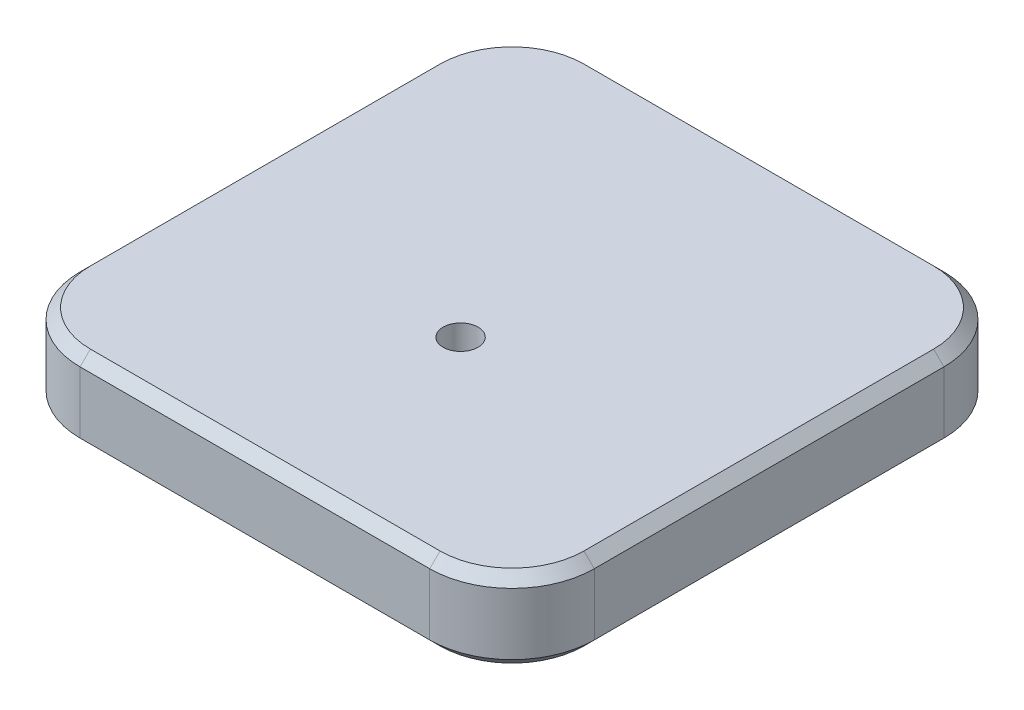
from build123d import *

# Parameters (mm, degrees)
SKETCH1_W                      = 25
SKETCH1_H                      = 25
BOSS_EXTRUDE1_DEPTH            = 4
FILLET1_R                      = 4
F_1_7_1_7_DIAMETER_HOLE1_D     = 1.7
F_1_7_1_7_DIAMETER_HOLE1_DEPTH = 8.5
CHAMFER1_SIZE                  = 0.5


with BuildPart() as part:
    # Sketch1 → Boss-Extrude1 (new body)
    with BuildSketch(Plane(origin=(0, 0, 0), x_dir=(1, 0, 0), z_dir=(0, 1, 0))):
        with Locations((-5.188287333, 3.444371681)):
            Rectangle(SKETCH1_W, SKETCH1_H)
    extrude(amount=BOSS_EXTRUDE1_DEPTH)

    # Fillet1
    fillet1_edges = [part.edges().sort_by_distance(p)[0] for p in [
        (-17.688287333, 2, -15.944371681),
        (7.311712667, 2, -15.944371681),
        (7.311712667, 2, 9.055628319),
        (-17.688287333, 2, 9.055628319),
    ]]
    fillet(fillet1_edges, radius=FILLET1_R)

    # Ø1.7 (1.7) Diameter Hole1
    with Locations(Plane(origin=(-5.188287333, 4, -0.944371681), x_dir=(0, 0, 1), z_dir=(0, 1, 0))):
        with Locations((0, 0)):
            Hole(F_1_7_1_7_DIAMETER_HOLE1_D / 2, depth=F_1_7_1_7_DIAMETER_HOLE1_DEPTH)

    # Chamfer1
    chamfer1_edges = [part.edges().sort_by_distance(p)[0] for p in [
        (-17.688287333, 0, -3.444371681),
        (-17.688287333, 4, -3.444371681),
        (-5.188287333, 0, -15.944371681),
        (7.311712667, 0, -3.444371681),
        (-5.188287333, 0, 9.055628319),
        (-16.516714458, 0, 7.884055444),
        (6.140139792, 0, 7.884055444),
        (6.140139792, 0, -14.772798805),
        (-16.516714458, 0, -14.772798805),
        (-5.188287333, 4, -15.944371681),
        (-5.188287333, 4, 9.055628319),
        (7.311712667, 4, -3.444371681),
        (-16.516714458, 4, 7.884055444),
        (6.140139792, 4, 7.884055444),
        (6.140139792, 4, -14.772798805),
        (-16.516714458, 4, -14.772798805),
    ]]
    chamfer(chamfer1_edges, length=CHAMFER1_SIZE)


solid = part.part
